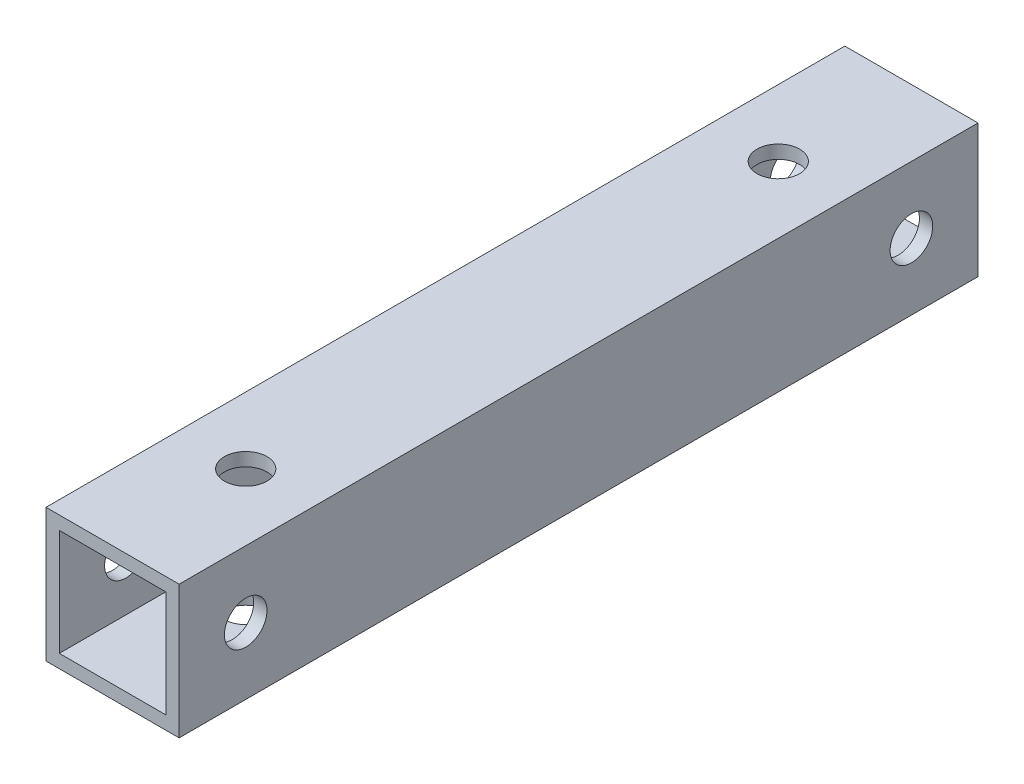
from build123d import *

# Parameters (mm, degrees)
SKETCH_1_W          = 10
SKETCH_1_H          = 10
SKETCH_1_W_2        = 8
SKETCH_1_H_2        = 8
EXTRUDE_1_DEPTH     = 30
SKETCH_3_R          = 1.6
CUT_EXTRUDE_1_DEPTH = 11
SKETCH_4_R          = 1.6
CUT_EXTRUDE_2_DEPTH = 11


with BuildPart() as part:
    # ｽｹｯﾁ1 → ﾎﾞｽ - 押し出し1 (new body, symmetric)
    with BuildSketch(Plane.XY):
        Rectangle(SKETCH_1_W, SKETCH_1_H)
        Rectangle(SKETCH_1_W_2, SKETCH_1_H_2, mode=Mode.SUBTRACT)
    extrude(amount=EXTRUDE_1_DEPTH, both=True)

    # ｽｹｯﾁ3 → ｶｯﾄ - 押し出し1 (cut, through all)
    with BuildSketch(Plane(origin=(5, 0, 0), x_dir=(0, 0, -1), z_dir=(1, 0, 0))):
        with Locations((-25, 0)):
            Circle(SKETCH_3_R)
        with Locations((25, 0)):
            Circle(SKETCH_3_R)
    extrude(amount=-CUT_EXTRUDE_1_DEPTH, mode=Mode.SUBTRACT)

    # ｽｹｯﾁ4 → ｶｯﾄ - 押し出し2 (cut, through all)
    with BuildSketch(Plane(origin=(0, 5, 0), x_dir=(1, 0, 0), z_dir=(0, 1, 0))):
        with Locations((0, -20)):
            Circle(SKETCH_4_R)
        with Locations((0, 20)):
            Circle(SKETCH_4_R)
    extrude(amount=-CUT_EXTRUDE_2_DEPTH, mode=Mode.SUBTRACT)


solid = part.part
